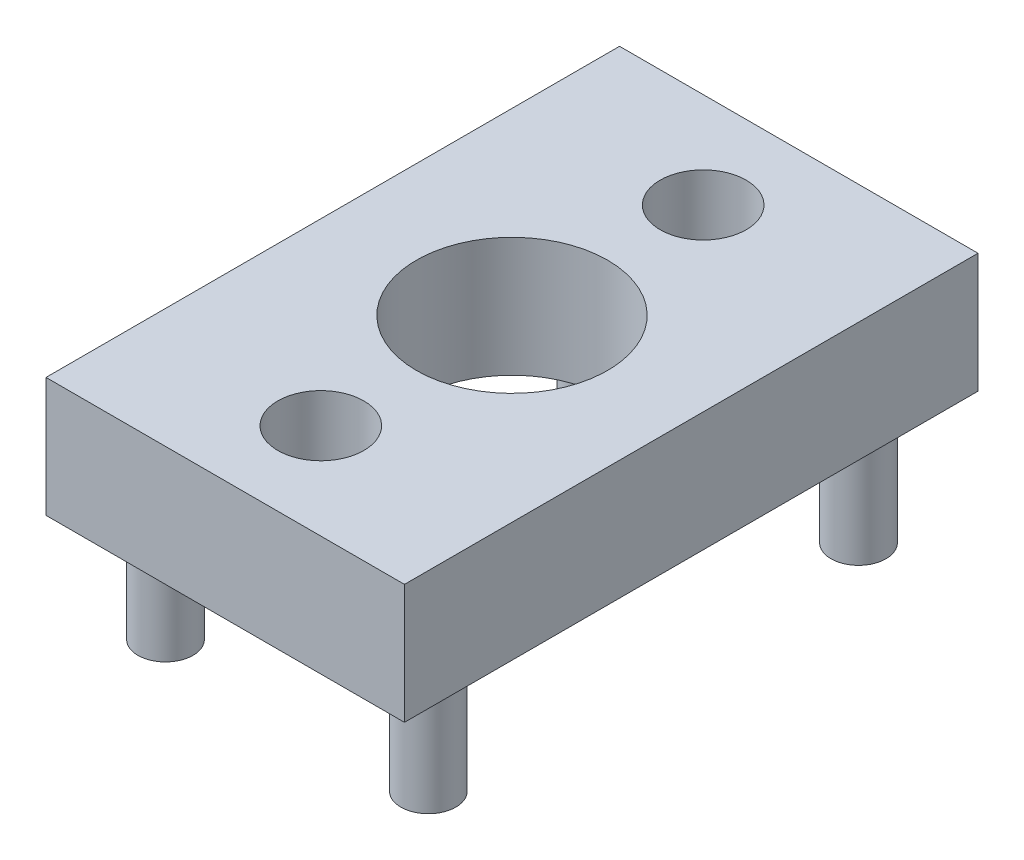
from build123d import *

# Parameters (mm, degrees)
SKETCH1_W                                = 24
SKETCH1_H                                = 5
BOSS_EXTRUDE1_DEPTH                      = 15
SKETCH2_R                                = 1.15
BOSS_EXTRUDE2_DEPTH                      = 5
SKETCH4_R                                = 4
CUT_EXTRUDE1_DEPTH                       = 11
CBORE_FOR_M3_PAN_HEAD_SCREW1_D           = 3.6
CBORE_FOR_M3_PAN_HEAD_SCREW1_CBORE_D     = 7
CBORE_FOR_M3_PAN_HEAD_SCREW1_CBORE_DEPTH = 2.4


with BuildPart() as part:
    # Sketch1 → Boss-Extrude1 (new body)
    with BuildSketch(Plane(origin=(0, 0, 0), x_dir=(0, 0, -1), z_dir=(1, 0, 0))):
        Rectangle(SKETCH1_W, SKETCH1_H)
    extrude(amount=BOSS_EXTRUDE1_DEPTH)

    # Sketch2 → Boss-Extrude2 (add)
    with BuildSketch(Plane.XZ.offset(2.5)):
        with Locations((2, 9)):
            Circle(SKETCH2_R)
        with Locations((13, 9)):
            Circle(SKETCH2_R)
        with Locations((13, -9)):
            Circle(SKETCH2_R)
        with Locations((2, -9)):
            Circle(SKETCH2_R)
    extrude(amount=BOSS_EXTRUDE2_DEPTH)

    # Sketch4 → Cut-Extrude1 (cut, through all)
    with BuildSketch(Plane(origin=(0, 2.5, 0), x_dir=(1, 0, 0), z_dir=(0, 1, 0))):
        with Locations((7.5, 0)):
            Circle(SKETCH4_R)
    extrude(amount=-CUT_EXTRUDE1_DEPTH, mode=Mode.SUBTRACT)

    # CBORE for M3 Pan Head Screw1 (through all)
    with Locations(Plane(origin=(0, -2.5, 0), x_dir=(-1, 0, 0), z_dir=(0, -1, 0))):
        with Locations((-7.5, 8), (-7.5, -8)):
            CounterBoreHole(CBORE_FOR_M3_PAN_HEAD_SCREW1_D / 2, CBORE_FOR_M3_PAN_HEAD_SCREW1_CBORE_D / 2, CBORE_FOR_M3_PAN_HEAD_SCREW1_CBORE_DEPTH)


solid = part.part
